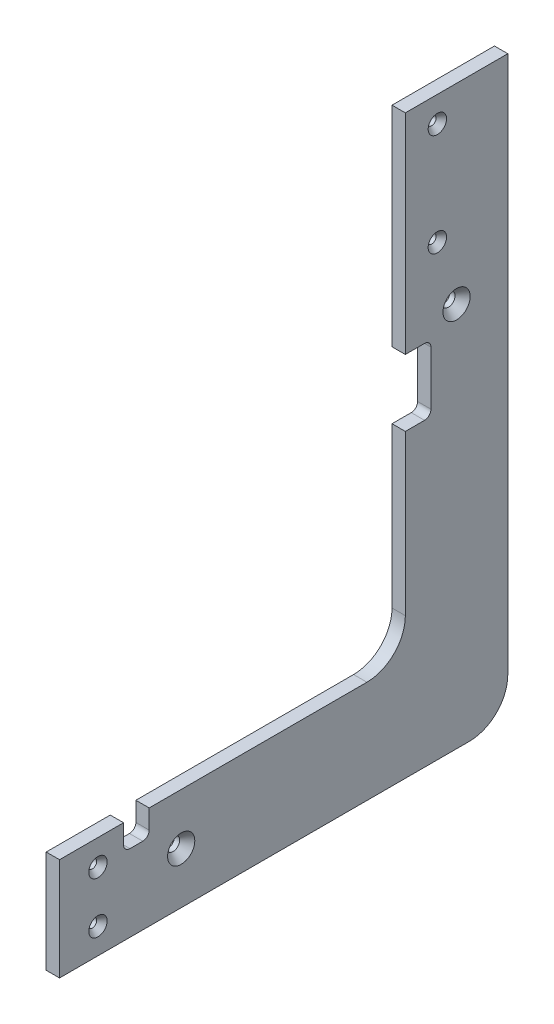
from build123d import *

# Parameters (mm, degrees)
BOSS_EXTRUDE2_DEPTH                               = 6.604
CSK_FOR_8_FLAT_HEAD_SOCKET_CAP_SCREW1_D           = 4.3053
CSK_FOR_8_FLAT_HEAD_SOCKET_CAP_SCREW1_CSINK_D     = 9.1186
CSK_FOR_8_FLAT_HEAD_SOCKET_CAP_SCREW1_CSINK_ANGLE = 82
CSK_FOR_8_FLAT_HEAD_SOCKET_CAP_SCREW2_D           = 4.3053
CSK_FOR_8_FLAT_HEAD_SOCKET_CAP_SCREW2_CSINK_D     = 9.1186
CSK_FOR_8_FLAT_HEAD_SOCKET_CAP_SCREW2_CSINK_ANGLE = 82
CSK_FOR_1_4_FLAT_HEAD_SOCKET_CAP_SCR_2_COUNT      = 2
CSK_FOR_1_4_FLAT_HEAD_SOCKET_CAP_SCR_2_PITCH      = 214.529804424
CUT_EXTRUDE1_DEPTH                                = 7.604


with BuildPart() as part:
    # Sketch1 → Boss-Extrude2 (new body)
    with BuildSketch(Plane(origin=(0, 0, 0), x_dir=(0, 0, -1), z_dir=(1, 0, 0))):
        with BuildLine():
            Line((0, -234.95), (0, -285.75))
            Line((0, -285.75), (203.2, -285.75))
            ThreePointArc((203.2, -285.75), (216.670384182, -280.170384182), (222.25, -266.7))
            Line((222.25, -266.7), (222.25, 0))
            Line((222.25, 0), (171.45, 0))
            Line((171.45, 0), (171.45, -215.9))
            ThreePointArc((171.45, -215.9), (165.870384182, -229.370384182), (152.4, -234.95))
            Line((152.4, -234.95), (0, -234.95))
        make_face()
    extrude(amount=BOSS_EXTRUDE2_DEPTH)

    # CSK for #8 Flat Head Socket Cap Screw1 (through all)
    with Locations(Plane(origin=(6.604, -103.971373163, -28.9631092), x_dir=(0, 0, 1), z_dir=(1, 0, 0))):
        with Locations((-158.3618908, -91.271373163), (-158.3618908, -40.471373163)):
            CounterSinkHole(CSK_FOR_8_FLAT_HEAD_SOCKET_CAP_SCREW1_D / 2, CSK_FOR_8_FLAT_HEAD_SOCKET_CAP_SCREW1_CSINK_D / 2, counter_sink_angle=CSK_FOR_8_FLAT_HEAD_SOCKET_CAP_SCREW1_CSINK_ANGLE)

    # CSK for #8 Flat Head Socket Cap Screw2 (through all)
    with Locations(Plane(origin=(6.604, 143.822396254, -169.282653802), x_dir=(0, 0, 1), z_dir=(1, 0, 0))):
        with Locations((150.232653802, 391.472396254), (150.232653802, 416.872396254)):
            CounterSinkHole(CSK_FOR_8_FLAT_HEAD_SOCKET_CAP_SCREW2_D / 2, CSK_FOR_8_FLAT_HEAD_SOCKET_CAP_SCREW2_CSINK_D / 2, counter_sink_angle=CSK_FOR_8_FLAT_HEAD_SOCKET_CAP_SCREW2_CSINK_ANGLE)

    # Sketch9 → CSK for 1/4 Flat Head Socket Cap Screw1 (revolve, cut)
    with BuildSketch(Plane(origin=(6.604, -94.869, -196.85), x_dir=(0, 0, -1), z_dir=(0, 1, 0))):
        Polygon((0, 0), (0, 6.604), (3.2639, 6.604), (3.2639, 4.003051983), (6.7437, 0), align=None)
    csk_for_1_4_flat_head_socket_cap_screw1 = revolve(axis=Axis((12.954, -94.869, -196.85), (-1, 0, 0)), mode=Mode.SUBTRACT)

    # CSK for 1_4 Flat Head Socket Cap Scr 2: CSK for 1/4 Flat Head Socket Cap Screw1 ×2
    with Locations(*[Vector(0, -0.771366013, 0.636391761) * (i * CSK_FOR_1_4_FLAT_HEAD_SOCKET_CAP_SCR_2_PITCH) for i in range(1, CSK_FOR_1_4_FLAT_HEAD_SOCKET_CAP_SCR_2_COUNT)]):
        add(csk_for_1_4_flat_head_socket_cap_screw1, mode=Mode.SUBTRACT)

    # Sketch11 → Cut-Extrude1 (cut, through all)
    with BuildSketch(Plane.ZY):
        with BuildLine():
            Line((-171.45, -103.759), (-180.975, -103.759))
            ThreePointArc((-180.975, -103.759), (-183.22006403, -104.68893597), (-184.15, -106.934))
            Line((-184.15, -106.934), (-184.15, -133.604))
            ThreePointArc((-184.15, -133.604), (-183.22006403, -135.84906403), (-180.975, -136.779))
            Line((-180.975, -136.779), (-171.45, -136.779))
            Line((-171.45, -136.779), (-171.45, -103.759))
        make_face()
        with BuildLine():
            Line((-44.45, -234.95), (-31.75, -234.95))
            Line((-31.75, -234.95), (-31.75, -244.475))
            ThreePointArc((-31.75, -244.475), (-32.67993597, -246.72006403), (-34.925, -247.65))
            Line((-34.925, -247.65), (-41.275, -247.65))
            ThreePointArc((-41.275, -247.65), (-43.52006403, -246.72006403), (-44.45, -244.475))
            Line((-44.45, -244.475), (-44.45, -234.95))
        make_face()
    extrude(amount=-CUT_EXTRUDE1_DEPTH, mode=Mode.SUBTRACT)


solid = part.part
